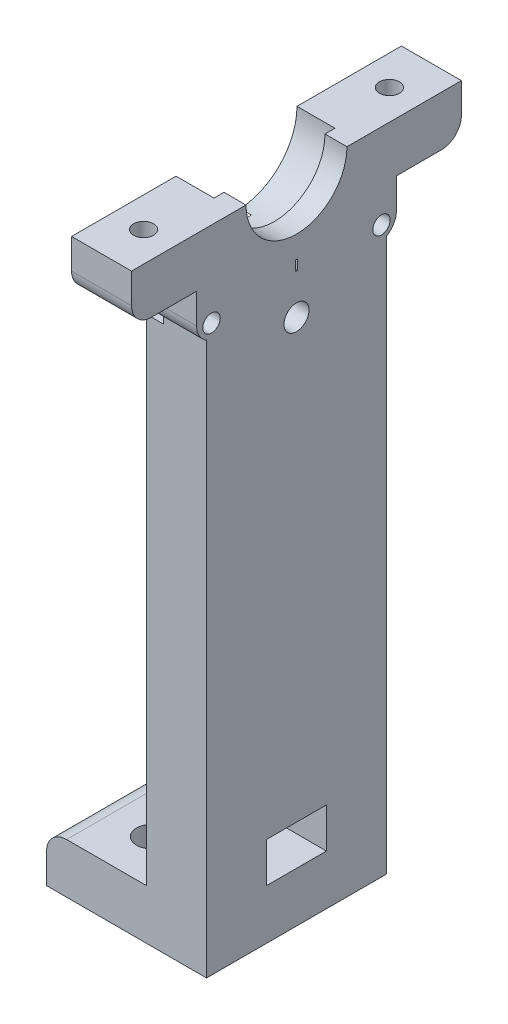
from build123d import *

# Parameters (mm, degrees)
SKETCH1_R                 = 17.45
SKETCH1_R_2               = 12.45
BOSS_EXTRUDE1_DEPTH       = 8
SKETCH2_R                 = 20
SKETCH2_R_2               = 12.45
BOSS_EXTRUDE2_DEPTH       = 2
SKETCH3_R                 = 32.5
SKETCH3_R_2               = 12.45
BOSS_EXTRUDE3_DEPTH       = 4
FILLET1_R                 = 1
BOSS_EXTRUDE6_START       = -4
SKETCH10_W                = 10
SKETCH10_H                = 18
BOSS_EXTRUDE6_DEPTH       = 4
SKETCH4_W                 = 6
SKETCH4_H                 = 18
BOSS_EXTRUDE4_DEPTH       = 75
BOSS_EXTRUDE4_DEPTH_BACK  = 4
SKETCH5_R                 = 5.05
CUT_EXTRUDE1_DEPTH        = 306
CUT_EXTRUDE1_DEPTH_BACK   = 113
SKETCH6_W                 = 6
SKETCH6_H                 = 10
BOSS_EXTRUDE5_DEPTH       = 15
BOSS_EXTRUDE5_DEPTH_BACK  = 32.85
SKETCH7_R                 = 1.629220746
SKETCH7_R_2               = 1.580258945
CUT_EXTRUDE2_DEPTH        = 10
SKETCH9_R                 = 5.05
CUT_EXTRUDE3_DEPTH        = 10
CUT_EXTRUDE3_DEPTH_BACK   = 10
SKETCH11_W                = 9.782596874
SKETCH11_H                = 3.234517514
CUT_EXTRUDE4_DEPTH        = 123
CUT_EXTRUDE4_DEPTH_BACK   = 61
FILLET4_R                 = 3
FILLET5_R                 = 3
SKETCH12_W                = 108.791398151
SKETCH12_H                = 24.041848298
CUT_EXTRUDE5_DEPTH        = 110.678
SKETCH15_R                = 22
CUT_EXTRUDE7_DEPTH        = 4
SKETCH13_R                = 22
SKETCH13_R_2              = 11
SKETCH13_R_3              = 2.75
BOSS_EXTRUDE7_DEPTH       = 4
FILLET6_R                 = 3
CUT_EXTRUDE8_DEPTH        = 5
FILLET7_R                 = 1
BOSS_EXTRUDE8_START       = -3
BOSS_EXTRUDE8_DEPTH       = 9.4
FILLET8_R                 = 3
FILLET8_OF_MIRROR2_R      = 3
CUT_EXTRUDE12_START       = -6
SKETCH21_R                = 6.05
CUT_EXTRUDE12_DEPTH       = 3.8
SKETCH18_W                = 88.746975794
SKETCH18_H                = 20.386854219
CUT_EXTRUDE9_DEPTH        = 10
SKETCH19_W                = 6
SKETCH19_H                = 10.45
BOSS_EXTRUDE9_DEPTH       = 5
FILLET9_R                 = 2
CUT_EXTRUDE13_DEPTH       = 2
SKETCH23_R                = 1
CUT_EXTRUDE14_DEPTH       = 11
CUT_EXTRUDE16_DEPTH       = 1.7
CUT_EXTRUDE17_DEPTH       = 55
CUT_EXTRUDE17_DEPTH_BACK  = 127
SKETCH26_W                = 18
SKETCH26_H                = 5
BOSS_EXTRUDE10_DEPTH      = 10
BOSS_EXTRUDE10_DEPTH_BACK = 6
FILLET10_R                = 2
SKETCH27_W                = 6
SKETCH27_H                = 4
CUT_EXTRUDE18_DEPTH       = 10
SKETCH28_R                = 1.5
CUT_EXTRUDE19_DEPTH       = 10
BOSS_EXTRUDE11_DEPTH      = 6
SKETCH30_R                = 0.870021032
CUT_EXTRUDE20_DEPTH       = 6
CUT_EXTRUDE21_DEPTH       = 1.7
SKETCH32_R                = 1.5
CUT_EXTRUDE22_DEPTH       = 5
SKETCH33_W                = 0.2
SKETCH33_H                = 1
CUT_EXTRUDE23_DEPTH       = 5
SKETCH34_R                = 1.755
CUT_EXTRUDE24_DEPTH       = 1.1
SKETCH35_R                = 1.25
CUT_EXTRUDE25_DEPTH       = 11.1


with BuildPart() as part:
    # Sketch1 → Boss-Extrude1 (new body)
    with BuildSketch(Plane(origin=(0, 0, 0), x_dir=(1, 0, 0), z_dir=(0, 1, 0))):
        Circle(SKETCH1_R)
        Circle(SKETCH1_R_2, mode=Mode.SUBTRACT)
    extrude(amount=BOSS_EXTRUDE1_DEPTH)

    # Sketch2 → Boss-Extrude2 (add)
    with BuildSketch(Plane(origin=(0, 8, 0), x_dir=(1, 0, 0), z_dir=(0, 1, 0))):
        Circle(SKETCH2_R)
        Circle(SKETCH2_R_2, mode=Mode.SUBTRACT)
    extrude(amount=BOSS_EXTRUDE2_DEPTH)

    # Sketch3 → Boss-Extrude3 (add)
    with BuildSketch(Plane(origin=(0, 10, 0), x_dir=(1, 0, 0), z_dir=(0, 1, 0))):
        Circle(SKETCH3_R)
        Circle(SKETCH3_R_2, mode=Mode.SUBTRACT)
    extrude(amount=BOSS_EXTRUDE3_DEPTH)

    # Fillet1
    fillet1_edges = [part.edges().sort_by_distance(p)[0] for p in [
        (-32.5, 14, 0),
    ]]
    fillet(fillet1_edges, radius=FILLET1_R)

    # Sketch10 → Boss-Extrude6 (add)
    with BuildSketch(Plane(origin=(0, 14, 0), x_dir=(1, 0, 0), z_dir=(0, 1, 0)).offset(BOSS_EXTRUDE6_START)):
        with Locations((35.186917696, 0)):
            Rectangle(SKETCH10_W, SKETCH10_H)
        with Locations((-35.186917696, 0)):
            Rectangle(SKETCH10_W, SKETCH10_H)
    extrude(amount=BOSS_EXTRUDE6_DEPTH)

    # Sketch4 → Boss-Extrude4 (add, two sides)
    with BuildSketch(Plane(origin=(0, 14, 0), x_dir=(1, 0, 0), z_dir=(0, 1, 0))) as boss_extrude4_sk:
        with Locations((-37.186917696, 0)):
            Rectangle(SKETCH4_W, SKETCH4_H)
        with Locations((37.186917696, 0)):
            Rectangle(SKETCH4_W, SKETCH4_H)
    extrude(amount=BOSS_EXTRUDE4_DEPTH)
    extrude(boss_extrude4_sk.sketch, amount=-BOSS_EXTRUDE4_DEPTH_BACK)

    # Sketch5 → Cut-Extrude1 (cut, two sides)
    with BuildSketch(Plane.ZY.offset(-34.186917696)) as cut_extrude1_sk:
        with Locations((0, 79)):
            Circle(SKETCH5_R)
    extrude(amount=CUT_EXTRUDE1_DEPTH, mode=Mode.SUBTRACT)
    extrude(cut_extrude1_sk.sketch, amount=-CUT_EXTRUDE1_DEPTH_BACK, mode=Mode.SUBTRACT)

    # Sketch6 → Boss-Extrude5 (add, two sides)
    with BuildSketch(Plane(origin=(0, 0, -9), x_dir=(-1, 0, 0), z_dir=(0, 0, -1))) as boss_extrude5_sk:
        with Locations((37.186917696, 70.95)):
            Rectangle(SKETCH6_W, SKETCH6_H)
    extrude(amount=BOSS_EXTRUDE5_DEPTH)
    extrude(boss_extrude5_sk.sketch, amount=-BOSS_EXTRUDE5_DEPTH_BACK)

    # Sketch7 → Cut-Extrude2 (cut)
    with BuildSketch(Plane(origin=(-34.186917696, 0, 0), x_dir=(0, 0, -1), z_dir=(1, 0, 0))):
        with Locations((-17.5, 71)):
            Circle(SKETCH7_R)
        with Locations((17.5, 71)):
            Circle(SKETCH7_R_2)
    extrude(amount=-CUT_EXTRUDE2_DEPTH, mode=Mode.SUBTRACT)

    # Sketch9 → Cut-Extrude3 (cut, two sides)
    with BuildSketch(Plane(origin=(-34.186917696, 0, 0), x_dir=(0, 0, -1), z_dir=(1, 0, 0))) as cut_extrude3_sk:
        with Locations((0, 79)):
            Circle(SKETCH9_R)
    extrude(amount=CUT_EXTRUDE3_DEPTH, mode=Mode.SUBTRACT)
    extrude(cut_extrude3_sk.sketch, amount=-CUT_EXTRUDE3_DEPTH_BACK, mode=Mode.SUBTRACT)

    # Sketch11 → Cut-Extrude4 (cut, two sides)
    with BuildSketch(Plane.ZY.offset(-34.186917696)) as cut_extrude4_sk:
        with Locations((0, 15.617258757)):
            Rectangle(SKETCH11_W, SKETCH11_H)
    extrude(amount=CUT_EXTRUDE4_DEPTH, mode=Mode.SUBTRACT)
    extrude(cut_extrude4_sk.sketch, amount=-CUT_EXTRUDE4_DEPTH_BACK, mode=Mode.SUBTRACT)

    # Fillet4
    fillet4_edges = [part.edges().sort_by_distance(p)[0] for p in [
        (-37.186917696, 65.95, 23.85),
        (-37.186917696, 75.95, 23.85),
        (-37.186917696, 65.95, -24),
        (-37.186917696, 75.95, -24),
        (-37.186917696, 89, -9),
        (-37.186917696, 89, 9),
    ]]
    fillet(fillet4_edges, radius=FILLET4_R)

    # Fillet5
    fillet5_edges = [part.edges().sort_by_distance(p)[0] for p in [
        (40.186917696, 10, 0),
        (-40.186917696, 10, 0),
    ]]
    fillet(fillet5_edges, radius=FILLET5_R)

    # Sketch12 → Cut-Extrude5 (cut)
    with BuildSketch(Plane(origin=(40.186917696, 0, 0), x_dir=(0, 0, -1), z_dir=(1, 0, 0))):
        with Locations((-12.502918017, -2.020924149)):
            Rectangle(SKETCH12_W, SKETCH12_H)
    extrude(amount=-CUT_EXTRUDE5_DEPTH, mode=Mode.SUBTRACT)

    # Sketch15 → Cut-Extrude7 (cut)
    with BuildSketch(Plane(origin=(0, 14, 0), x_dir=(1, 0, 0), z_dir=(0, 1, 0))):
        Circle(SKETCH15_R)
    extrude(amount=-CUT_EXTRUDE7_DEPTH, mode=Mode.SUBTRACT)

    # Sketch13 → Boss-Extrude7 (add)
    with BuildSketch(Plane(origin=(0, 14, 0), x_dir=(1, 0, 0), z_dir=(0, 1, 0))):
        Circle(SKETCH13_R)
        Circle(SKETCH13_R_2, mode=Mode.SUBTRACT)
        with Locations((0, 17.5)):
            Circle(SKETCH13_R_3, mode=Mode.SUBTRACT)
        with Locations((-15.155444566, -8.75)):
            Circle(SKETCH13_R_3, mode=Mode.SUBTRACT)
        with Locations((15.155444566, -8.75)):
            Circle(SKETCH13_R_3, mode=Mode.SUBTRACT)
    extrude(amount=-BOSS_EXTRUDE7_DEPTH)

    # Fillet6
    fillet6_edges = [part.edges().sort_by_distance(p)[0] for p in [
        (37.186917696, 89, 9),
        (37.186917696, 89, -9),
    ]]
    fillet(fillet6_edges, radius=FILLET6_R)

    # Sketch16 → Cut-Extrude8 (cut)
    with BuildSketch(Plane.XZ.offset(-10)):
        with BuildLine():
            Line((-31.228992939, 9), (-20.29384143, 9))
            ThreePointArc((-20.29384143, 9), (0, 22.2), (20.29384143, 9))
            Line((20.29384143, 9), (31.228992939, 9))
            ThreePointArc((31.228992939, 9), (0, 32.5), (-31.228992939, 9))
        make_face()
    cut_extrude8 = extrude(amount=-CUT_EXTRUDE8_DEPTH, mode=Mode.SUBTRACT)

    # Mirror1: Cut-Extrude8 across plane
    add(cut_extrude8.mirror(Plane.XY), mode=Mode.SUBTRACT)

    # Fillet7
    fillet7_edges = [part.edges().sort_by_distance(p)[0] for p in [
        (0, 14, 22.2),
        (0, 14, -22.2),
    ]]
    fillet(fillet7_edges, radius=FILLET7_R)

    # Sketch17 → Boss-Extrude8 (add)
    with BuildSketch(Plane.XZ.offset(-10).offset(BOSS_EXTRUDE8_START)):
        with BuildLine():
            Line((20.29384143, -9), (40.186917696, -9))
            Line((40.186917696, -9), (40.186917696, 9))
            Line((40.186917696, 9), (20.29384143, 9))
            ThreePointArc((20.29384143, 9), (22.2, 0), (20.29384143, -9))
        make_face()
    boss_extrude8 = extrude(amount=BOSS_EXTRUDE8_DEPTH)

    # Fillet8
    fillet8_edges = [part.edges().sort_by_distance(p)[0] for p in [
        (40.186917696, 3.6, 0),
    ]]
    fillet(fillet8_edges, radius=FILLET8_R)

    # Mirror2: Boss-Extrude8 across plane
    add(boss_extrude8.mirror(Plane(origin=(0, 0, 0), x_dir=(0, 0, 1), z_dir=(1, 0, 0))))

    # Fillet8 of Mirror2
    fillet8_of_mirror2_edges = [part.edges().sort_by_distance(p)[0] for p in [
        (-40.186917696, 3.6, 0),
    ]]
    fillet(fillet8_of_mirror2_edges, radius=FILLET8_OF_MIRROR2_R)

    # Sketch21 → Cut-Extrude12 (cut)
    with BuildSketch(Plane(origin=(40.186917696, 0, 0), x_dir=(0, 0, -1), z_dir=(1, 0, 0)).offset(CUT_EXTRUDE12_START)):
        with Locations((0, 79)):
            Circle(SKETCH21_R)
    extrude(amount=CUT_EXTRUDE12_DEPTH, mode=Mode.SUBTRACT)

    # Sketch18 → Cut-Extrude9 (cut)
    with BuildSketch(Plane(origin=(40.186917696, 0, 0), x_dir=(0, 0, -1), z_dir=(1, 0, 0))):
        with Locations((0, 89.193427109)):
            Rectangle(SKETCH18_W, SKETCH18_H)
    extrude(amount=-CUT_EXTRUDE9_DEPTH, mode=Mode.SUBTRACT)

    # Sketch19 → Boss-Extrude9 (add)
    with BuildSketch(Plane(origin=(0, 79, 0), x_dir=(1, 0, 0), z_dir=(0, 1, 0))):
        with Locations((37.186917696, -11.275)):
            Rectangle(SKETCH19_W, SKETCH19_H)
        with Locations((37.186917696, 11.275)):
            Rectangle(SKETCH19_W, SKETCH19_H)
    extrude(amount=-BOSS_EXTRUDE9_DEPTH)

    # Fillet9
    fillet9_edges = [part.edges().sort_by_distance(p)[0] for p in [
        (37.186917696, 74, 16.5),
        (37.186917696, 74, -16.5),
    ]]
    fillet(fillet9_edges, radius=FILLET9_R)

    # Sketch22 → Cut-Extrude13 (cut)
    with BuildSketch(Plane(origin=(-34.186917696, 0, 0), x_dir=(0, 0, -1), z_dir=(1, 0, 0))):
        Polygon((-15.9988893, 68.4), (-14.4977786, 71), (-15.9988893, 73.6), (-19.0011107, 73.6), (-20.5022214, 71), (-19.0011107, 68.4), align=None)
        Polygon((20.5022214, 71), (19.0011107, 73.6), (15.9988893, 73.6), (14.4977786, 71), (15.9988893, 68.4), (19.0011107, 68.4), align=None)
    extrude(amount=-CUT_EXTRUDE13_DEPTH, mode=Mode.SUBTRACT)

    # Sketch23 → Cut-Extrude14 (cut)
    with BuildSketch(Plane(origin=(0, 79, 0), x_dir=(1, 0, 0), z_dir=(0, 1, 0))):
        with Locations((37.186917696, -12.3)):
            Circle(SKETCH23_R)
        with Locations((37.186917696, 12.3)):
            Circle(SKETCH23_R)
    extrude(amount=-CUT_EXTRUDE14_DEPTH, mode=Mode.SUBTRACT)

    # Sketch24 → Cut-Extrude16 (cut)
    with BuildSketch(Plane.XZ.offset(-74)):
        Polygon((37.186917696, 9.990598923), (39.186917696, 11.145299462), (39.186917696, 13.454700538), (37.186917696, 14.609401077), (35.186917696, 13.454700538), (35.186917696, 11.145299462), align=None)
        Polygon((37.186917696, -14.609401077), (39.186917696, -13.454700538), (39.186917696, -11.145299462), (37.186917696, -9.990598923), (35.186917696, -11.145299462), (35.186917696, -13.454700538), align=None)
    extrude(amount=-CUT_EXTRUDE16_DEPTH, mode=Mode.SUBTRACT)

    # Sketch25 → Cut-Extrude17 (cut, two sides)
    with BuildSketch(Plane.XY.offset(9)) as cut_extrude17_sk:
        Polygon((34.186917696, 121.100331415), (-54.647701705, 121.100331415), (-54.647701705, -34.206054819), (60.966679658, -34.206054819), (60.966679658, 14), (34.186917696, 14), align=None)
    extrude(amount=CUT_EXTRUDE17_DEPTH, mode=Mode.SUBTRACT)
    extrude(cut_extrude17_sk.sketch, amount=-CUT_EXTRUDE17_DEPTH_BACK, mode=Mode.SUBTRACT)

    # Sketch26 → Boss-Extrude10 (add, two sides)
    with BuildSketch(Plane.ZY.offset(-34.186917696)) as boss_extrude10_sk:
        with Locations((0, 16.5)):
            Rectangle(SKETCH26_W, SKETCH26_H)
    extrude(amount=BOSS_EXTRUDE10_DEPTH)
    extrude(boss_extrude10_sk.sketch, amount=-BOSS_EXTRUDE10_DEPTH_BACK)

    # Fillet10
    fillet10_edges = [part.edges().sort_by_distance(p)[0] for p in [
        (24.186917696, 19, 0),
    ]]
    fillet(fillet10_edges, radius=FILLET10_R)

    # Sketch27 → Cut-Extrude18 (cut)
    with BuildSketch(Plane.ZY.offset(-34.186917696)):
        with Locations((0, 21)):
            Rectangle(SKETCH27_W, SKETCH27_H)
    extrude(amount=-CUT_EXTRUDE18_DEPTH, mode=Mode.SUBTRACT)

    # Sketch28 → Cut-Extrude19 (cut)
    with BuildSketch(Plane(origin=(0, 19, 0), x_dir=(1, 0, 0), z_dir=(0, 1, 0))):
        with Locations((30.186917696, 4.5)):
            Circle(SKETCH28_R)
        with Locations((30.186917696, -4.5)):
            Circle(SKETCH28_R)
    extrude(amount=-CUT_EXTRUDE19_DEPTH, mode=Mode.SUBTRACT)

    # Sketch29 → Boss-Extrude11 (add)
    with BuildSketch(Plane.ZY.offset(-34.186917696)):
        with BuildLine():
            Line((-6.05, 79), (-10, 79))
            Line((-10, 79), (-10, 71))
            ThreePointArc((-10, 71), (-9.414213562, 69.585786438), (-8, 69))
            Line((-8, 69), (8, 69))
            ThreePointArc((8, 69), (9.414213562, 69.585786438), (10, 71))
            Line((10, 71), (10, 79))
            Line((10, 79), (6.05, 79))
            Line((6.05, 79), (6.05, 71.902838549))
            Line((6.05, 71.902838549), (-6.05, 71.902838549))
            Line((-6.05, 71.902838549), (-6.05, 79))
        make_face()
    extrude(amount=-BOSS_EXTRUDE11_DEPTH)

    # Sketch30 → Cut-Extrude20 (cut)
    with BuildSketch(Plane.ZY.offset(-34.186917696)):
        with Locations((-8.5, 70.5)):
            Circle(SKETCH30_R)
        with Locations((8.5, 70.5)):
            Circle(SKETCH30_R)
    extrude(amount=-CUT_EXTRUDE20_DEPTH, mode=Mode.SUBTRACT)

    # Sketch31 → Cut-Extrude21 (cut)
    with BuildSketch(Plane.ZY.offset(-34.186917696)):
        Polygon((-7.345299462, 68.5), (-6.190598923, 70.5), (-7.345299462, 72.5), (-9.654700538, 72.5), (-10.809401077, 70.5), (-9.654700538, 68.5), align=None)
        Polygon((9.654700538, 68.5), (10.809401077, 70.5), (9.654700538, 72.5), (7.345299462, 72.5), (6.190598923, 70.5), (7.345299462, 68.5), align=None)
    extrude(amount=-CUT_EXTRUDE21_DEPTH, mode=Mode.SUBTRACT)

    # Sketch32 → Cut-Extrude22 (cut)
    with BuildSketch(Plane.ZY.offset(-34.186917696)):
        with Locations((0, 71.25)):
            Circle(SKETCH32_R)
    extrude(amount=-CUT_EXTRUDE22_DEPTH, mode=Mode.SUBTRACT)

    # Sketch33 → Cut-Extrude23 (cut)
    with BuildSketch(Plane.ZY.offset(-39.186917696)):
        with Locations((0, 71.25)):
            Rectangle(SKETCH33_W, SKETCH33_H)
    extrude(amount=-CUT_EXTRUDE23_DEPTH, mode=Mode.SUBTRACT)

    # Sketch34 → Cut-Extrude24 (cut)
    with BuildSketch(Plane.ZY.offset(-34.186917696)):
        with Locations((0, 71.25)):
            Circle(SKETCH34_R)
    extrude(amount=-CUT_EXTRUDE24_DEPTH, mode=Mode.SUBTRACT)

    # Sketch35 → Cut-Extrude25 (cut)
    with BuildSketch(Plane.ZY.offset(-34.186917696)):
        with Locations((0, 66.75)):
            Circle(SKETCH35_R)
    extrude(amount=-CUT_EXTRUDE25_DEPTH, mode=Mode.SUBTRACT)


solid = part.part
